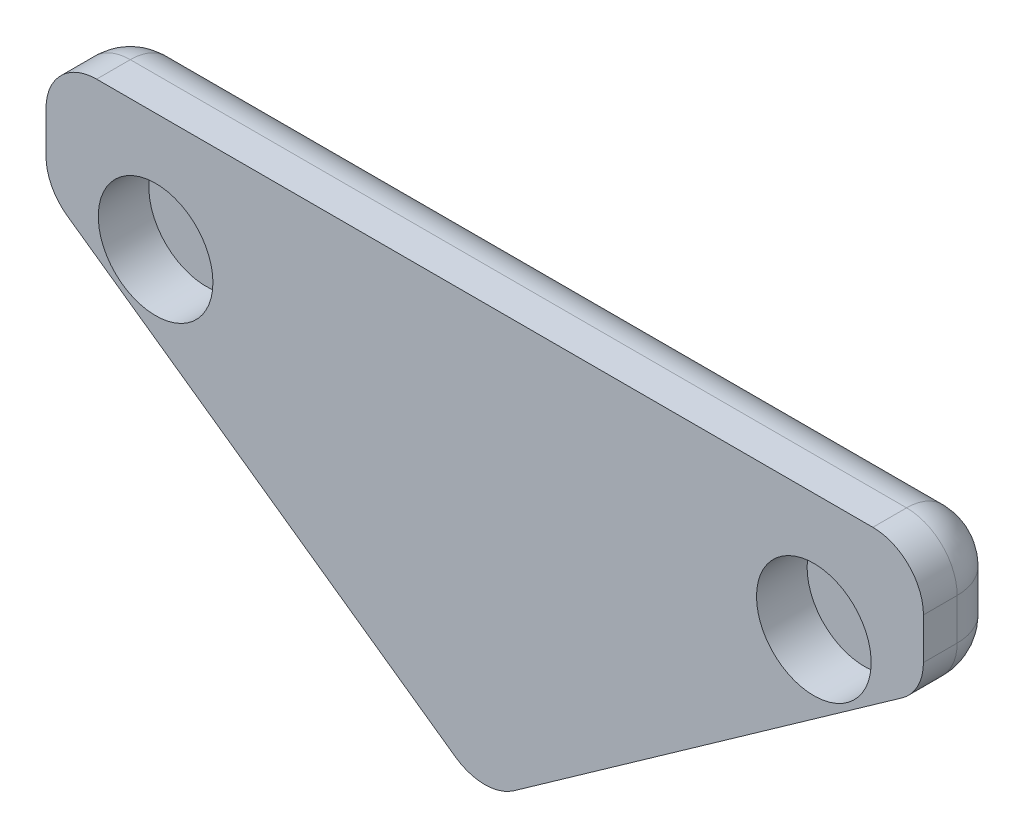
from build123d import *

# Parameters (mm, degrees)
BOSS_EXTRUDE1_DEPTH = 2.5
SKETCH2_R           = 1.7
CUT_EXTRUDE1_DEPTH  = 1.5
FILLET1_R           = 1.5


with BuildPart() as part:
    # Sketch1 → Boss-Extrude1 (new body)
    with BuildSketch(Plane.XY):
        Polygon((-7.56419618, 12.7), (-7.56419618, 9.2), (5.44580382, 0), (5.44580382, 12.7), align=None)
    extrude(amount=BOSS_EXTRUDE1_DEPTH)

    # Sketch2 → Cut-Extrude1 (cut)
    with BuildSketch(Plane.XY.offset(2.5)):
        with Locations((-4.31419618, 9.2)):
            Circle(SKETCH2_R)
    extrude(amount=-CUT_EXTRUDE1_DEPTH, mode=Mode.SUBTRACT)

    # Mirror2: part across plane


with BuildPart() as part_1:
    add(part.part)
    add(part.part.mirror(Plane(origin=(5.44580382, 0, 2.5), x_dir=(0, 0, 1), z_dir=(-1, 0, 0))))

    # Fillet1
    fillet1_edges = [part_1.edges().sort_by_distance(p)[0] for p in [
        (18.45580382, 12.7, 1.25),
        (18.45580382, 9.2, 1.25),
        (5.44580382, 0, 1.25),
        (18.45580382, 10.95, 0),
        (11.95080382, 4.6, 0),
        (-1.05919618, 4.6, 0),
        (-7.56419618, 10.95, 0),
        (5.44580382, 12.7, 0),
        (-7.56419618, 9.2, 1.25),
        (-7.56419618, 12.7, 1.25),
    ]]
    fillet(fillet1_edges, radius=FILLET1_R)


solid = part_1.part
